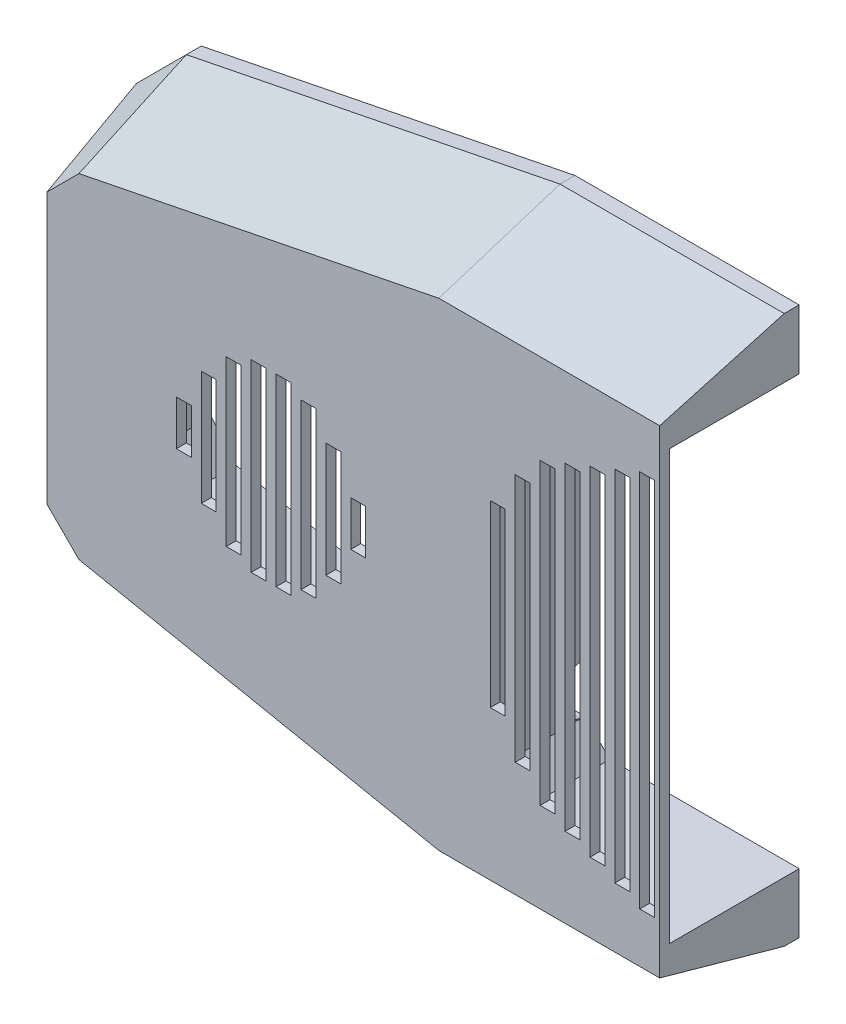
from build123d import *
from OCP.BRepFilletAPI import BRepFilletAPI_MakeChamfer

# Parameters (mm, degrees)
ESBO_O1_W                 = 2
ESBO_O1_H                 = 86
RESSALTO_EXTRUS_O3_DEPTH  = 25
RESSALTO_EXTRUS_O16_DEPTH = 25
RESSALTO_EXTRUS_O17_DEPTH = 28
CHANFRO6_SIZE             = 25
CHANFRO6_SIZE2            = 7
RESSALTO_EXTRUS_O19_DEPTH = 25
ESBO_O9_R                 = 1
CORTE_EXTRUS_O1_DEPTH     = 10
ESBO_O13_W                = 5
ESBO_O13_H                = 10
ESBO_O13_W_2              = 3
ESBO_O13_H_2              = 46.8
CORTE_EXTRUS_O6_DEPTH     = 256.564081983
CORTE_EXTRUS_O8_REACH     = 185.679
CORTE_EXTRUS_O9_REACH     = 185.679
CORTE_EXTRUS_O10_REACH    = 257.564
ESBO_O14_W                = 3
ESBO_O14_H                = 46.8
RESSALTO_EXTRUS_O20_DEPTH = 3
CORTE_EXTRUS_O13_DEPTH    = 3
ESBO_O23_W                = 3
ESBO_O23_H                = 4.5
CORTE_EXTRUS_O14_DEPTH    = 3
CORTE_EXTRUS_O15_REACH    = 145.906
ESBO_O24_W                = 130
ESBO_O24_H                = 110
CORTE_EXTRUS_O16_DEPTH    = 1
CORTE_EXTRUS_O17_DEPTH    = 1


with BuildPart() as part:
    # Esboço1 → Ressalto-extrusão3 (new body)
    with BuildSketch(Plane.XY):
        Polygon((-45, -43), (-120, -28), (-120, -30), (-45, -45), (45, -45), (45, -43), (43, -43), (-43, -43), align=None)
        with Locations((44, 0)):
            Rectangle(ESBO_O1_W, ESBO_O1_H)
        Polygon((45, 45), (-45, 45), (-45, 43), (-43, 43), (43, 43), (45, 43), align=None)
        with Locations((-44, 0)):
            Rectangle(ESBO_O1_W, ESBO_O1_H)
        Polygon((-120, 30), (-120, 28), (-45, 43), (-45, 45), align=None)
        Polygon((-45, -43), (-120, -28), (-120, -30), (-45, -45), (45, -45), (45, -43), (43, -43), (-43, -43), align=None)
        Polygon((120, -28), (45, -43), (45, -45), (120, -30), align=None)
        Polygon((120, 30), (45, 45), (45, 43), (120, 28), align=None)
    extrude(amount=RESSALTO_EXTRUS_O3_DEPTH)

    # Esboço6 → Ressalto-extrusão16 (add)
    with BuildSketch(Plane.XY):
        Polygon((-120, -28), (-120, 28), (-118, 28.4), (-118, -28.4), align=None)
        Polygon((120, 28), (120, -28), (118, -28.4), (118, 28.4), align=None)
    extrude(amount=RESSALTO_EXTRUS_O16_DEPTH)

    # Esboço7 → Ressalto-extrusão17 (add)
    with BuildSketch(Plane.XY):
        Polygon((-120, 40), (-45, 55), (45, 55), (120, 40), (130, 30), (130, -30), (120, -40), (45, -55), (-45, -55), (-120, -40), (-130, -30), (-130, 30), align=None)
        Polygon((-45, -45), (45, -45), (120, -30), (120, 30), (45, 45), (-45, 45), (-120, 30), (-120, -30), align=None, mode=Mode.SUBTRACT)
    extrude(amount=RESSALTO_EXTRUS_O17_DEPTH)

    # Chanfro6: one chamfer whose edges measure the first distance from different faces: ONE call of the kernel's chamfer builder (chamfer() names one face for all edges)
    chanfro6_edges_1 = [part.edges().sort_by_distance(p)[0] for p in [
        (82.5, -47.5, 28),
    ]]
    chanfro6_side_1 = [part.faces().sort_by_distance(p)[0] for p in [
        (82.5, -47.5, 14),
    ]]
    chanfro6_edges_2 = [part.edges().sort_by_distance(p)[0] for p in [
        (125, -35, 28),
    ]]
    chanfro6_side_2 = [part.faces().sort_by_distance(p)[0] for p in [
        (125, -35, 14),
    ]]
    chanfro6_edges_3 = [part.edges().sort_by_distance(p)[0] for p in [
        (130, 0, 28),
    ]]
    chanfro6_side_3 = [part.faces().sort_by_distance(p)[0] for p in [
        (130, 0, 14),
    ]]
    chanfro6_edges_4 = [part.edges().sort_by_distance(p)[0] for p in [
        (125, 35, 28),
    ]]
    chanfro6_side_4 = [part.faces().sort_by_distance(p)[0] for p in [
        (125, 35, 14),
    ]]
    chanfro6_edges_5 = [part.edges().sort_by_distance(p)[0] for p in [
        (82.5, 47.5, 28),
    ]]
    chanfro6_side_5 = [part.faces().sort_by_distance(p)[0] for p in [
        (82.5, 47.5, 14),
    ]]
    chanfro6_edges_6 = [part.edges().sort_by_distance(p)[0] for p in [
        (0, 55, 28),
    ]]
    chanfro6_side_6 = [part.faces().sort_by_distance(p)[0] for p in [
        (0, 55, 14),
    ]]
    chanfro6_edges_7 = [part.edges().sort_by_distance(p)[0] for p in [
        (-82.5, 47.5, 28),
    ]]
    chanfro6_side_7 = [part.faces().sort_by_distance(p)[0] for p in [
        (-82.5, 47.5, 14),
    ]]
    chanfro6_edges_8 = [part.edges().sort_by_distance(p)[0] for p in [
        (-125, 35, 28),
    ]]
    chanfro6_side_8 = [part.faces().sort_by_distance(p)[0] for p in [
        (-125, 35, 14),
    ]]
    chanfro6_edges_9 = [part.edges().sort_by_distance(p)[0] for p in [
        (-130, 0, 28),
    ]]
    chanfro6_side_9 = [part.faces().sort_by_distance(p)[0] for p in [
        (-130, 0, 14),
    ]]
    chanfro6_edges_10 = [part.edges().sort_by_distance(p)[0] for p in [
        (-125, -35, 28),
    ]]
    chanfro6_side_10 = [part.faces().sort_by_distance(p)[0] for p in [
        (-125, -35, 14),
    ]]
    chanfro6_edges_11 = [part.edges().sort_by_distance(p)[0] for p in [
        (-82.5, -47.5, 28),
    ]]
    chanfro6_side_11 = [part.faces().sort_by_distance(p)[0] for p in [
        (-82.5, -47.5, 14),
    ]]
    chanfro6_edges_12 = [part.edges().sort_by_distance(p)[0] for p in [
        (0, -55, 28),
    ]]
    chanfro6_side_12 = [part.faces().sort_by_distance(p)[0] for p in [
        (0, -55, 14),
    ]]
    chanfro6 = BRepFilletAPI_MakeChamfer(part.part.solid().wrapped)
    for e in chanfro6_edges_1:
        chanfro6.Add(CHANFRO6_SIZE, CHANFRO6_SIZE2, e.wrapped, chanfro6_side_1[0].wrapped)  # the first distance lies on this face
    for e in chanfro6_edges_2:
        chanfro6.Add(CHANFRO6_SIZE, CHANFRO6_SIZE2, e.wrapped, chanfro6_side_2[0].wrapped)  # the first distance lies on this face
    for e in chanfro6_edges_3:
        chanfro6.Add(CHANFRO6_SIZE, CHANFRO6_SIZE2, e.wrapped, chanfro6_side_3[0].wrapped)  # the first distance lies on this face
    for e in chanfro6_edges_4:
        chanfro6.Add(CHANFRO6_SIZE, CHANFRO6_SIZE2, e.wrapped, chanfro6_side_4[0].wrapped)  # the first distance lies on this face
    for e in chanfro6_edges_5:
        chanfro6.Add(CHANFRO6_SIZE, CHANFRO6_SIZE2, e.wrapped, chanfro6_side_5[0].wrapped)  # the first distance lies on this face
    for e in chanfro6_edges_6:
        chanfro6.Add(CHANFRO6_SIZE, CHANFRO6_SIZE2, e.wrapped, chanfro6_side_6[0].wrapped)  # the first distance lies on this face
    for e in chanfro6_edges_7:
        chanfro6.Add(CHANFRO6_SIZE, CHANFRO6_SIZE2, e.wrapped, chanfro6_side_7[0].wrapped)  # the first distance lies on this face
    for e in chanfro6_edges_8:
        chanfro6.Add(CHANFRO6_SIZE, CHANFRO6_SIZE2, e.wrapped, chanfro6_side_8[0].wrapped)  # the first distance lies on this face
    for e in chanfro6_edges_9:
        chanfro6.Add(CHANFRO6_SIZE, CHANFRO6_SIZE2, e.wrapped, chanfro6_side_9[0].wrapped)  # the first distance lies on this face
    for e in chanfro6_edges_10:
        chanfro6.Add(CHANFRO6_SIZE, CHANFRO6_SIZE2, e.wrapped, chanfro6_side_10[0].wrapped)  # the first distance lies on this face
    for e in chanfro6_edges_11:
        chanfro6.Add(CHANFRO6_SIZE, CHANFRO6_SIZE2, e.wrapped, chanfro6_side_11[0].wrapped)  # the first distance lies on this face
    for e in chanfro6_edges_12:
        chanfro6.Add(CHANFRO6_SIZE, CHANFRO6_SIZE2, e.wrapped, chanfro6_side_12[0].wrapped)  # the first distance lies on this face
    add(Compound.cast(chanfro6.Shape()), mode=Mode.REPLACE)

    # Esboço8 → Ressalto-extrusão19 (add)
    with BuildSketch(Plane.XY):
        Polygon((-118, 28.4), (-118, 23.4), (-113, 29.4), align=None)
        Polygon((-45, 38), (-45, 43), (-50, 42), align=None)
        Polygon((-49.902903378, -42.019419324), (-45, -43), (-45, -38), align=None)
        Polygon((-118, -23.4), (-118, -28.4), (-113, -29.4), align=None)
        Polygon((118, 23.4), (118, 28.4), (113, 29.4), align=None)
        Polygon((113, -29.4), (118, -28.4), (118, -23.4), align=None)
        Polygon((45, -38), (45, -43), (50, -42), align=None)
        Polygon((50, 42), (45, 43), (45, 38), align=None)
        Polygon((-43, -38), (-43, -43), (-38, -43), align=None)
        Polygon((-38, 43), (-43, 43), (-43, 38), align=None)
        Polygon((43, 38), (43, 43), (38, 43), align=None)
        Polygon((38, -43), (43, -43), (43, -38), align=None)
    extrude(amount=RESSALTO_EXTRUS_O19_DEPTH)

    # Esboço9 → Corte-extrusão1 (cut)
    with BuildSketch(Plane(origin=(0, 0, 0), x_dir=(-1, 0, 0), z_dir=(0, 0, -1))):
        with Locations((44.126560345, -45)):
            Circle(ESBO_O9_R)
        with Locations((-44.233718703, -45)):
            Circle(ESBO_O9_R)
        with Locations((-44.233718703, 45)):
            Circle(ESBO_O9_R)
        with Locations((44.233718703, 45)):
            Circle(ESBO_O9_R)
        with Locations((120, -30)):
            Circle(ESBO_O9_R)
        with Locations((120, 30)):
            Circle(ESBO_O9_R)
        with Locations((-120, 30)):
            Circle(ESBO_O9_R)
        with Locations((-120, -30)):
            Circle(ESBO_O9_R)
    extrude(amount=-CORTE_EXTRUS_O1_DEPTH, mode=Mode.SUBTRACT)

    # Esboço13 → Corte-extrusão6 (cut, through all)
    with BuildSketch(Plane.ZY.offset(-118)):
        with Locations((2.5, 0)):
            Rectangle(ESBO_O13_W, ESBO_O13_H)
        with Locations((21.5, 0)):
            Rectangle(ESBO_O13_W_2, ESBO_O13_H_2)
        with Locations((16.5, 0)):
            Rectangle(ESBO_O13_W_2, ESBO_O13_H_2)
        with Locations((11.5, 0)):
            Rectangle(ESBO_O13_W_2, ESBO_O13_H_2)
    extrude(amount=-CORTE_EXTRUS_O6_DEPTH, mode=Mode.SUBTRACT)

    # Esboço15 → Corte-extrusão8 (cut, up to next)
    with BuildSketch(Plane.ZY.offset(-43), mode=Mode.PRIVATE) as corte_extrus_o8_sk1:
        with BuildLine():
            ThreePointArc((0, -38), (2.5, -35.5), (0, -33))
            Line((0, -33), (0, -38))
        make_face()
    corte_extrus_o8_tool1 = extrude(corte_extrus_o8_sk1.sketch, amount=-CORTE_EXTRUS_O8_REACH, mode=Mode.PRIVATE) & part.part
    # Esboço15 → Corte-extrusão8 (cut, up to next)
    with BuildSketch(Plane.ZY.offset(-43), mode=Mode.PRIVATE) as corte_extrus_o8_sk2:
        with BuildLine():
            ThreePointArc((0, 33), (2.5, 35.5), (0, 38))
            Line((0, 38), (0, 33))
        make_face()
    corte_extrus_o8_tool2 = extrude(corte_extrus_o8_sk2.sketch, amount=-CORTE_EXTRUS_O8_REACH, mode=Mode.PRIVATE) & part.part
    add(corte_extrus_o8_tool1.solids().sort_by_distance((43, -35.5, 1.061033))[0], mode=Mode.SUBTRACT)
    add(corte_extrus_o8_tool2.solids().sort_by_distance((43, 35.5, 1.061033))[0], mode=Mode.SUBTRACT)

    # Esboço16 → Corte-extrusão9 (cut, up to next)
    with BuildSketch(Plane(origin=(-43, 0, 0), x_dir=(0, 0, -1), z_dir=(1, 0, 0)), mode=Mode.PRIVATE) as corte_extrus_o9_sk1:
        with BuildLine():
            ThreePointArc((0, -28), (-5, -33), (0, -38))
            Line((0, -38), (0, -28))
        make_face()
    corte_extrus_o9_tool1 = extrude(corte_extrus_o9_sk1.sketch, amount=-CORTE_EXTRUS_O9_REACH, mode=Mode.PRIVATE) & part.part
    # Esboço16 → Corte-extrusão9 (cut, up to next)
    with BuildSketch(Plane(origin=(-43, 0, 0), x_dir=(0, 0, -1), z_dir=(1, 0, 0)), mode=Mode.PRIVATE) as corte_extrus_o9_sk2:
        with BuildLine():
            ThreePointArc((0, 38), (-5, 33), (0, 28))
            Line((0, 28), (0, 38))
        make_face()
    corte_extrus_o9_tool2 = extrude(corte_extrus_o9_sk2.sketch, amount=-CORTE_EXTRUS_O9_REACH, mode=Mode.PRIVATE) & part.part
    add(corte_extrus_o9_tool1.solids().sort_by_distance((-43, -33, 2.122066))[0], mode=Mode.SUBTRACT)
    add(corte_extrus_o9_tool2.solids().sort_by_distance((-43, 33, 2.122066))[0], mode=Mode.SUBTRACT)

    # Corte-extrusão10: up to this plane
    corte_extrus_o10_end = Plane(origin=(-123, -38, 28), z_dir=(-0.9629640197141827, 0, 0.2696299255199678))
    # Esboço14 → Corte-extrusão10 (cut, up to the surface)
    with BuildSketch(Plane(origin=(-118, 0, 0), x_dir=(0, 0, -1), z_dir=(1, 0, 0)), mode=Mode.PRIVATE) as corte_extrus_o10_sk1:
        with Locations((-21.5, 0)):
            Rectangle(ESBO_O14_W, ESBO_O14_H)
    corte_extrus_o10_tool1 = split(extrude(corte_extrus_o10_sk1.sketch, amount=-CORTE_EXTRUS_O10_REACH, mode=Mode.PRIVATE), bisect_by=corte_extrus_o10_end, keep=Keep.BOTH, mode=Mode.PRIVATE)
    add(corte_extrus_o10_tool1.solids().sort_by_distance((-118, 0, 21.5))[0], mode=Mode.SUBTRACT)
    # Esboço14 → Corte-extrusão10 (cut, up to the surface)
    with BuildSketch(Plane(origin=(-118, 0, 0), x_dir=(0, 0, -1), z_dir=(1, 0, 0)), mode=Mode.PRIVATE) as corte_extrus_o10_sk2:
        with Locations((-16.5, 0)):
            Rectangle(ESBO_O14_W, ESBO_O14_H)
    corte_extrus_o10_tool2 = split(extrude(corte_extrus_o10_sk2.sketch, amount=-CORTE_EXTRUS_O10_REACH, mode=Mode.PRIVATE), bisect_by=corte_extrus_o10_end, keep=Keep.BOTH, mode=Mode.PRIVATE)
    add(corte_extrus_o10_tool2.solids().sort_by_distance((-118, 0, 16.5))[0], mode=Mode.SUBTRACT)
    # Esboço14 → Corte-extrusão10 (cut, up to the surface)
    with BuildSketch(Plane(origin=(-118, 0, 0), x_dir=(0, 0, -1), z_dir=(1, 0, 0)), mode=Mode.PRIVATE) as corte_extrus_o10_sk3:
        Polygon((-13, 23.4), (-13, -23.4), (-12.5, -23.4), (-10, -23.4), (-10, 23.4), (-12.5, 23.4), align=None)
    corte_extrus_o10_tool3 = split(extrude(corte_extrus_o10_sk3.sketch, amount=-CORTE_EXTRUS_O10_REACH, mode=Mode.PRIVATE), bisect_by=corte_extrus_o10_end, keep=Keep.BOTH, mode=Mode.PRIVATE)
    add(corte_extrus_o10_tool3.solids().sort_by_distance((-118, 0, 11.5))[0], mode=Mode.SUBTRACT)
    # Esboço14 → Corte-extrusão10 (cut, up to the surface)
    with BuildSketch(Plane(origin=(-118, 0, 0), x_dir=(0, 0, -1), z_dir=(1, 0, 0)), mode=Mode.PRIVATE) as corte_extrus_o10_sk4:
        with Locations((-6.5, 0)):
            Rectangle(ESBO_O14_W, ESBO_O14_H)
    corte_extrus_o10_tool4 = split(extrude(corte_extrus_o10_sk4.sketch, amount=-CORTE_EXTRUS_O10_REACH, mode=Mode.PRIVATE), bisect_by=corte_extrus_o10_end, keep=Keep.BOTH, mode=Mode.PRIVATE)
    add(corte_extrus_o10_tool4.solids().sort_by_distance((-118, 0, 6.5))[0], mode=Mode.SUBTRACT)

    # Esboço20 → Ressalto-extrusão20 (add)
    with BuildSketch(Plane.XY.offset(28)):
        Polygon((-120, 30), (-45, 45), (45, 45), (120, 30), (120, -30), (45, -45), (-45, -45), (-120, -30), align=None)
    extrude(amount=-RESSALTO_EXTRUS_O20_DEPTH)

    # Esboço22 → Corte-extrusão13 (cut)
    with BuildSketch(Plane(origin=(0, 0, 25), x_dir=(-1, 0, 0), z_dir=(0, 0, -1))):
        Polygon((-33.799138949, -18), (-30.799138949, -18), (-30.799138949, 18), (-33.799138949, 18), (-33.799138949, 14), (-33.799138949, -14), align=None)
        Polygon((-28.799138949, -25), (-25.799138949, -25), (-25.799138949, 25), (-28.799138949, 25), (-28.799138949, 22), (-28.799138949, -22), align=None)
        Polygon((-24, -30), (-21, -30), (-21, 30), (-24, 30), (-24, 28), (-24, -28), align=None)
        Polygon((-19, -32), (-16, -32), (-16, 32), (-19, 32), (-19, 31), (-19, -31), align=None)
        Polygon((-14, -34), (-11, -34), (-11, 34), (-14, 34), (-14, 33), (-14, -33), align=None)
        Polygon((-9, -36), (-6, -36), (-6, 36), (-9, 36), (-9, 35), (-9, -35), align=None)
        Polygon((-4, -38), (-1, -38), (-1, 38), (-4, 38), (-4, 37), (-4, -37), align=None)
        Polygon((1, 38), (1, -38), (4, -38), (4, -37), (4, 37), (4, 38), align=None)
        Polygon((6, 36), (6, -36), (9, -36), (9, -35), (9, 35), (9, 36), align=None)
        Polygon((11, 34), (11, -34), (14, -34), (14, -33), (14, 33), (14, 34), align=None)
        Polygon((16, 32), (16, -32), (19, -32), (19, -31), (19, 31), (19, 32), align=None)
        Polygon((21, 30), (21, -30), (24, -30), (24, -28), (24, 28), (24, 30), align=None)
        Polygon((26, 25), (26, -25), (29, -25), (29, -22), (29, 22.932654574), (29, 25), align=None)
        Polygon((31, 18), (31, -18), (34, -18), (34, -14), (34, 14), (34, 18), align=None)
    extrude(amount=-CORTE_EXTRUS_O13_DEPTH, mode=Mode.SUBTRACT)

    # Esboço23 → Corte-extrusão14 (cut)
    with BuildSketch(Plane(origin=(0, 0, 25), x_dir=(-1, 0, 0), z_dir=(0, 0, -1))):
        with Locations((-60.5, -2.25)):
            Rectangle(ESBO_O23_W, ESBO_O23_H)
        with Locations((-60.5, 2.25)):
            Rectangle(ESBO_O23_W, ESBO_O23_H)
        Polygon((-67, 0), (-64, 0), (-64, 8.5), (-64, 11.5), (-67, 11.5), align=None)
        Polygon((-64, -8.5), (-64, 0), (-67, 0), (-67, -11.5), (-64, -11.5), align=None)
        Polygon((-72, 0), (-69, 0), (-69, 14.5), (-69, 16.5), (-72, 16.5), align=None)
        Polygon((-69, -14.5), (-69, 0), (-72, 0), (-72, -16.5), (-69, -16.5), align=None)
        Polygon((-74, -17.5), (-74, 0), (-77, 0), (-77, -18.5), (-74, -18.5), align=None)
        Polygon((-77, 0), (-74, 0), (-74, 17.5), (-74, 18.5), (-77, 18.5), align=None)
        Polygon((-82, 17.5), (-82, 0), (-79, 0), (-79, 18.5), (-82, 18.5), align=None)
        Polygon((-79, 0), (-82, 0), (-82, -17.5), (-82, -18.5), (-79, -18.5), align=None)
        Polygon((-84, 0), (-87, 0), (-87, -14.5), (-87, -16.5), (-84, -16.5), align=None)
        Polygon((-87, 14.5), (-87, 0), (-84, 0), (-84, 16.5), (-87, 16.5), align=None)
        Polygon((-92, 8.5), (-92, 0), (-89, 0), (-89, 11.5), (-92, 11.5), align=None)
        Polygon((-89, 0), (-92, 0), (-92, -8.5), (-92, -11.5), (-89, -11.5), align=None)
        with Locations((-95.5, 2.25)):
            Rectangle(ESBO_O23_W, ESBO_O23_H)
        with Locations((-95.5, -2.25)):
            Rectangle(ESBO_O23_W, ESBO_O23_H)
        with Locations((60.5, 2.25)):
            Rectangle(ESBO_O23_W, ESBO_O23_H)
        with Locations((60.5, -2.25)):
            Rectangle(ESBO_O23_W, ESBO_O23_H)
        Polygon((64, 8.5), (64, 0), (67, 0), (67, 11.5), (64, 11.5), align=None)
        Polygon((67, 0), (64, 0), (64, -8.5), (64, -11.5), (67, -11.5), align=None)
        Polygon((69, 14.5), (69, 0), (72, 0), (72, 16.5), (69, 16.5), align=None)
        Polygon((72, 0), (69, 0), (69, -14.5), (69, -16.5), (72, -16.5), align=None)
        Polygon((77, 0), (74, 0), (74, -17.5), (74, -18.5), (77, -18.5), align=None)
        Polygon((74, 17.5), (74, 0), (77, 0), (77, 18.5), (74, 18.5), align=None)
        Polygon((79, 0), (82, 0), (82, 17.5), (82, 18.5), (79, 18.5), align=None)
        Polygon((82, -17.5), (82, 0), (79, 0), (79, -18.5), (82, -18.5), align=None)
        Polygon((84, 0), (87, 0), (87, 14.5), (87, 16.5), (84, 16.5), align=None)
        Polygon((87, -14.5), (87, 0), (84, 0), (84, -16.5), (87, -16.5), align=None)
        Polygon((92, -8.5), (92, 0), (89, 0), (89, -11.5), (92, -11.5), align=None)
        with Locations((95.5, -2.25)):
            Rectangle(ESBO_O23_W, ESBO_O23_H)
        with Locations((95.5, 2.25)):
            Rectangle(ESBO_O23_W, ESBO_O23_H)
        Polygon((89, 0), (92, 0), (92, 8.5), (92, 11.5), (89, 11.5), align=None)
    extrude(amount=-CORTE_EXTRUS_O14_DEPTH, mode=Mode.SUBTRACT)

    # Esboço24 → Corte-extrusão15 (cut, up to next)
    with BuildSketch(Plane(origin=(0, 0, 0), x_dir=(-1, 0, 0), z_dir=(0, 0, -1)), mode=Mode.PRIVATE) as corte_extrus_o15_sk1:
        with Locations((-65, 0)):
            Rectangle(ESBO_O24_W, ESBO_O24_H)
    corte_extrus_o15_tool1 = extrude(corte_extrus_o15_sk1.sketch, amount=-CORTE_EXTRUS_O15_REACH, mode=Mode.PRIVATE) & part.part
    add(corte_extrus_o15_tool1.solids().sort_by_distance((65, 0, 0))[0], mode=Mode.SUBTRACT)

    # Esboço25 → Corte-extrusão16 (cut)
    with BuildSketch(Plane(origin=(0, 0, 25), x_dir=(-1, 0, 0), z_dir=(0, 0, -1))):
        Polygon((0, -43), (38, -43), (43, -38), (43, 38), (38, 43), (0, 43), align=None)
    extrude(amount=-CORTE_EXTRUS_O16_DEPTH, mode=Mode.SUBTRACT)

    # Esboço26 → Corte-extrusão17 (cut)
    with BuildSketch(Plane(origin=(0, 0, 25), x_dir=(-1, 0, 0), z_dir=(0, 0, -1))):
        Polygon((45, 38), (50, 42), (113, 29.4), (118, 23.4), (118, -23.4), (113, -29.4), (49.902903378, -42.019419324), (45, -38), align=None)
    extrude(amount=-CORTE_EXTRUS_O17_DEPTH, mode=Mode.SUBTRACT)


solid = part.part
